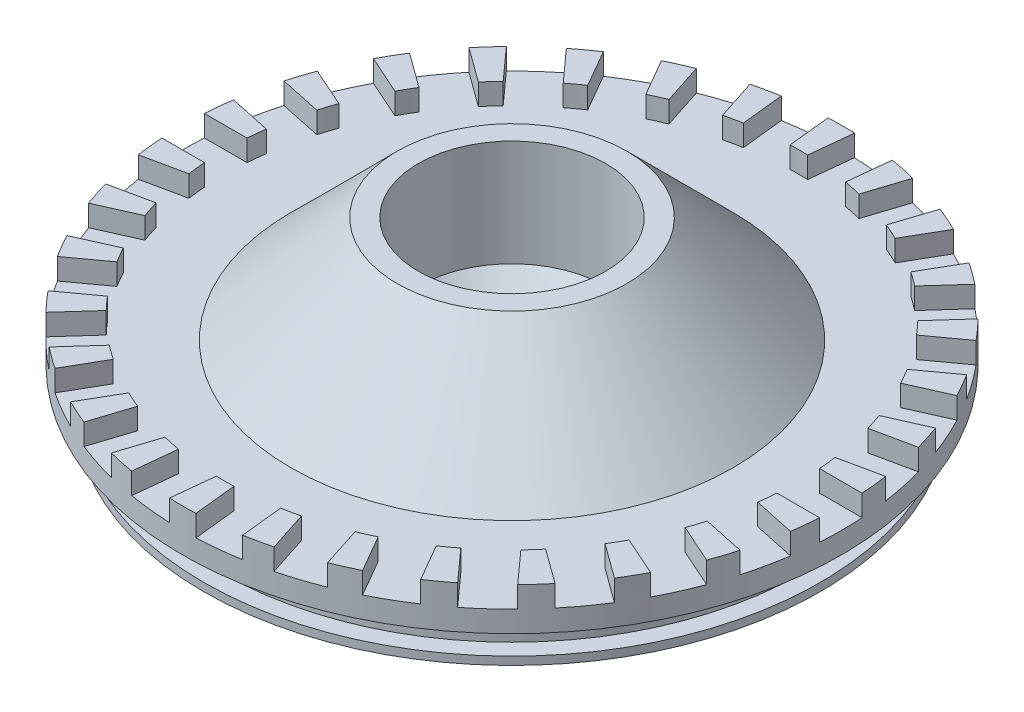
from build123d import *

# Parameters (mm, degrees)
SKETCH2_W          = 12.7
SKETCH2_H          = 6.35
CUT_EXTRUDE1_DEPTH = 3.175
CIRPATTERN1_COUNT  = 30


with BuildPart() as part:
    # Sketch1 → Revolve1 (revolve)
    with BuildSketch(Plane.XY):
        Polygon((-7.62, 0), (-46.0375, 0), (-46.0375, 1.2065), (-43.4975, 1.2065), (-43.4975, 4.7625), (-46.0375, 4.7625), (-46.0375, 6.35), (-49.2125, 6.35), (-49.2125, 12.7), (-42.8625, 12.7), (-42.8625, 9.525), (-33.02, 9.525), (-17.145, 25.4), (-13.97, 25.4), (-13.97, 9.525), (-7.62, 3.175), align=None)
    revolve(axis=Axis((0, -42.3, 0), (0, 1, 0)))

    # Sketch2 → Cut-Extrude1 (cut)
    with BuildSketch(Plane(origin=(0, 12.7, 0), x_dir=(1, 0, 0), z_dir=(0, 1, 0))):
        with Locations((49.094745657, 0)):
            Rectangle(SKETCH2_W, SKETCH2_H)
    cut_extrude1 = extrude(amount=-CUT_EXTRUDE1_DEPTH, mode=Mode.SUBTRACT)

    # CirPattern1: Cut-Extrude1 ×30 about axis
    cirpattern1_axis = Axis((0, 0, 0), (0, 1, 0))
    for i in range(1, CIRPATTERN1_COUNT):
        add(cut_extrude1.rotate(cirpattern1_axis, i * 360 / CIRPATTERN1_COUNT), mode=Mode.SUBTRACT)


solid = part.part
